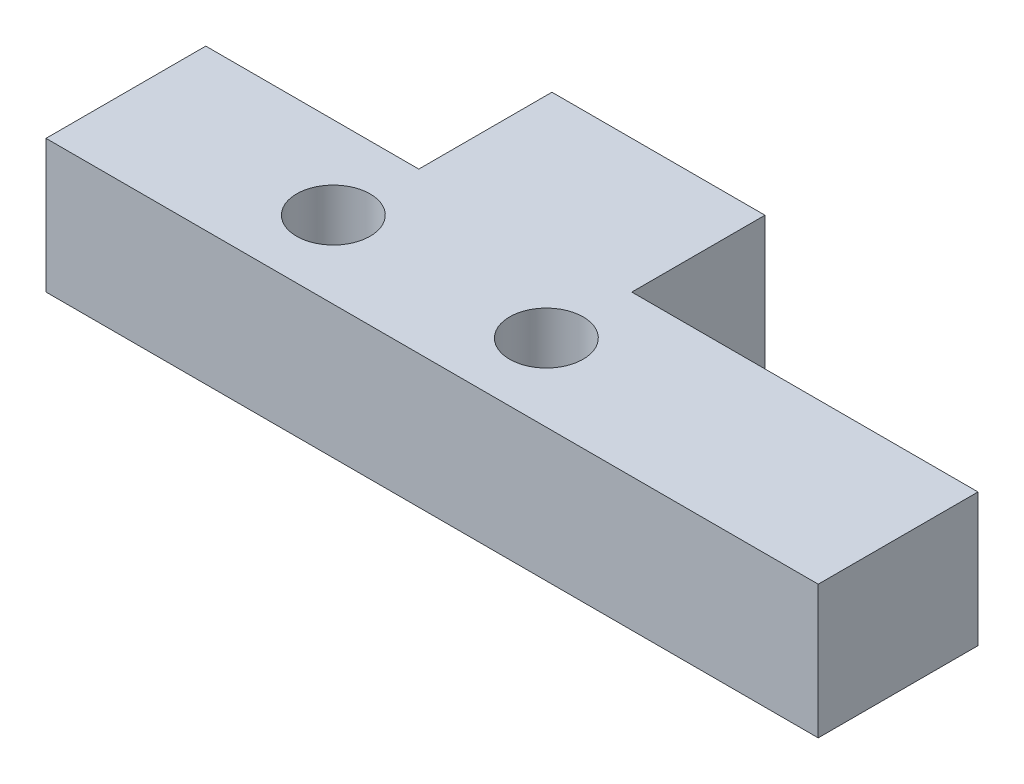
from build123d import *

# Parameters (mm, degrees)
SKETCH1_W           = 30.48
SKETCH1_H           = 7.62
BOSS_EXTRUDE1_DEPTH = 3.175
SKETCH2_W           = 10.16
SKETCH2_H           = 6.35
BOSS_EXTRUDE2_DEPTH = 6.35
SKETCH3_W           = 6.35
SKETCH3_H           = 7.62
BOSS_EXTRUDE3_DEPTH = 6.35
SKETCH6_R           = 1.7526
CUT_EXTRUDE1_DEPTH  = 7.35


with BuildPart() as part:
    # Sketch1 → Boss-Extrude1 (new body, symmetric)
    with BuildSketch(Plane(origin=(0, 0, 0), x_dir=(1, 0, 0), z_dir=(0, 1, 0))):
        Rectangle(SKETCH1_W, SKETCH1_H)
    extrude(amount=BOSS_EXTRUDE1_DEPTH, both=True)

    # Sketch2 → Boss-Extrude2 (add)
    with BuildSketch(Plane(origin=(0, 3.175, 0), x_dir=(1, 0, 0), z_dir=(0, 1, 0))):
        with Locations((0, 6.985)):
            Rectangle(SKETCH2_W, SKETCH2_H)
    extrude(amount=-BOSS_EXTRUDE2_DEPTH)

    # Sketch3 → Boss-Extrude3 (add)
    with BuildSketch(Plane(origin=(0, 3.175, 0), x_dir=(1, 0, 0), z_dir=(0, 1, 0))):
        with Locations((18.415, 0)):
            Rectangle(SKETCH3_W, SKETCH3_H)
    extrude(amount=-BOSS_EXTRUDE3_DEPTH)

    # Sketch6 → Cut-Extrude1 (cut, through all)
    with BuildSketch(Plane.XZ.offset(3.175)):
        with Locations((4.941550795, 0.127)):
            Circle(SKETCH6_R)
        with Locations((-5.218449205, 0.127)):
            Circle(SKETCH6_R)
    extrude(amount=-CUT_EXTRUDE1_DEPTH, mode=Mode.SUBTRACT)


solid = part.part
